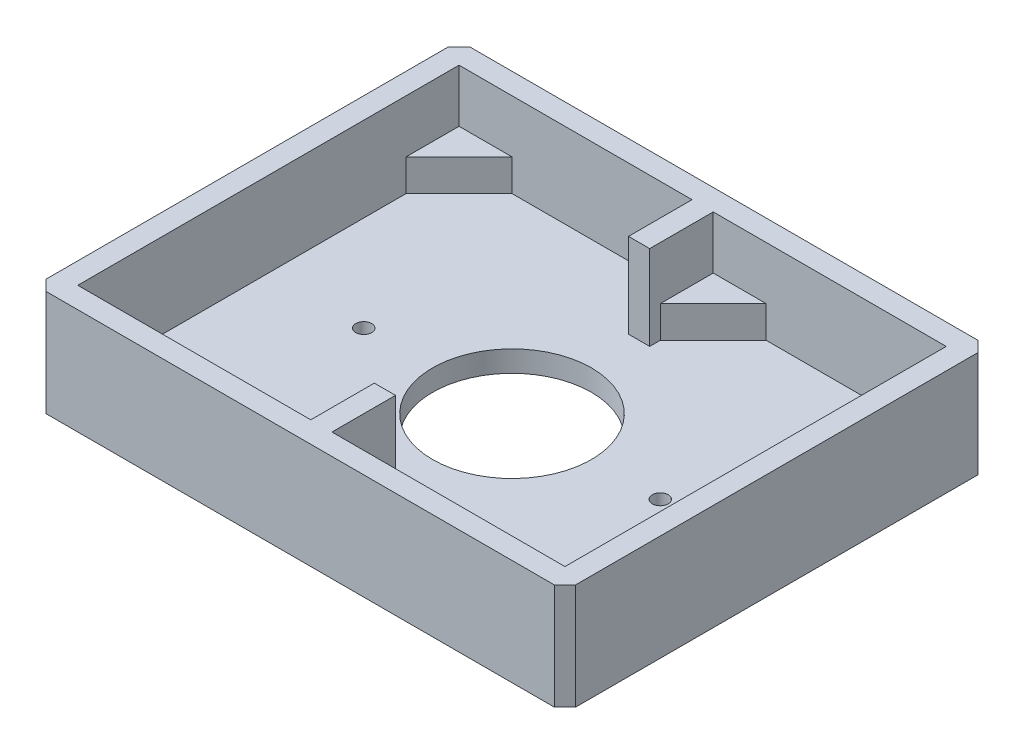
from build123d import *

# Parameters (mm, degrees)
SKETCH1_W           = 100
SKETCH1_H           = 80
BOSS_EXTRUDE1_DEPTH = 20
SHELL2_T            = -4
SKETCH14_W          = 4
SKETCH14_H          = 12
BOSS_EXTRUDE5_DEPTH = 16
SKETCH5_R           = 15
CUT_EXTRUDE1_DEPTH  = 5
BOSS_EXTRUDE6_DEPTH = 6
CHAMFER1_SIZE       = 2
SKETCH16_R          = 1.5
CUT_EXTRUDE2_DEPTH  = 4


with BuildPart() as part:
    # Sketch1 → Boss-Extrude1 (new body)
    with BuildSketch(Plane(origin=(0, 0, 0), x_dir=(1, 0, 0), z_dir=(0, 1, 0))):
        Rectangle(SKETCH1_W, SKETCH1_H)
    extrude(amount=-BOSS_EXTRUDE1_DEPTH)

    # Shell2
    shell2_openings = [part.faces().sort_by_distance(p)[0] for p in [
        (0, 0, 0),
    ]]
    offset(amount=SHELL2_T, openings=shell2_openings, kind=Kind.INTERSECTION)

    # Sketch14 → Boss-Extrude5 (add)
    with BuildSketch(Plane(origin=(0, 0, 0), x_dir=(1, 0, 0), z_dir=(0, 1, 0))):
        with Locations((0, -30)):
            Rectangle(SKETCH14_W, SKETCH14_H)
        with Locations((0, 30)):
            Rectangle(SKETCH14_W, SKETCH14_H)
    extrude(amount=-BOSS_EXTRUDE5_DEPTH)

    # Sketch5 → Cut-Extrude1 (cut, through all)
    with BuildSketch(Plane(origin=(0, -16, 0), x_dir=(1, 0, 0), z_dir=(0, 1, 0))):
        Circle(SKETCH5_R)
    extrude(amount=-CUT_EXTRUDE1_DEPTH, mode=Mode.SUBTRACT)

    # Sketch15 → Boss-Extrude6 (add)
    with BuildSketch(Plane(origin=(0, -16, 0), x_dir=(1, 0, 0), z_dir=(0, 1, 0))):
        Polygon((-46, 36), (-46, 26), (-36, 36), align=None)
        Polygon((-2, 36), (-2, 26), (-12, 36), align=None)
        Polygon((-2, -26), (-12, -36), (-2, -36), align=None)
        Polygon((-46, -26), (-36, -36), (-46, -36), align=None)
        Polygon((2, -36), (2, -26), (12, -36), align=None)
        Polygon((46, -36), (46, -26), (36, -36), align=None)
        Polygon((2, 26), (12, 36), (2, 36), align=None)
        Polygon((46, 26), (36, 36), (46, 36), align=None)
    extrude(amount=BOSS_EXTRUDE6_DEPTH)

    # Chamfer1
    chamfer1_edges = [part.edges().sort_by_distance(p)[0] for p in [
        (-50, -10, -40),
        (50, -10, -40),
        (50, -10, 40),
        (-50, -10, 40),
    ]]
    chamfer(chamfer1_edges, length=CHAMFER1_SIZE)

    # Sketch16 → Cut-Extrude2 (cut)
    with BuildSketch(Plane(origin=(0, -16, 0), x_dir=(1, 0, 0), z_dir=(0, 1, 0))):
        with Locations((-28, 0)):
            Circle(SKETCH16_R)
        with Locations((28, 0)):
            Circle(SKETCH16_R)
    extrude(amount=-CUT_EXTRUDE2_DEPTH, mode=Mode.SUBTRACT)


solid = part.part
